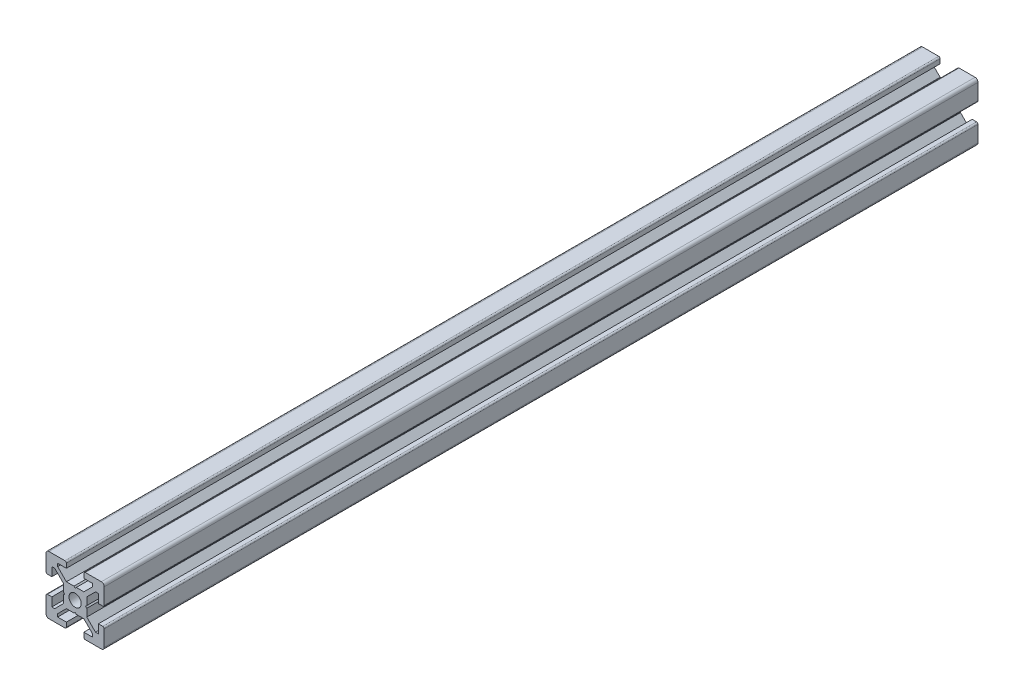
from build123d import *

# Parameters (mm, degrees)
SCHIZZO1_R                   = 2.1
ESTRUSIONE_ESTRUSIONE1_DEPTH = 300


with BuildPart() as part:
    # Schizzo1 → Estrusione-Estrusione1 (new body)
    with BuildSketch(Plane.XY):
        with BuildLine():
            Line((-3.6, 0), (-4, 0.4))
            Line((-4, 0.4), (-4, 3))
            Line((-4, 3), (-7, 6))
            Line((-7, 6), (-8, 6))
            Line((-8, 6), (-8, 3))
            Line((-8, 3), (-9.5, 3))
            ThreePointArc((-9.5, 3), (-9.853553391, 3.146446609), (-10, 3.5))
            Line((-10, 3.5), (-10, 9))
            ThreePointArc((-10, 9), (-9.707106781, 9.707106781), (-9, 10))
            Line((-9, 10), (-3.5, 10))
            ThreePointArc((-3.5, 10), (-3.146446609, 9.853553391), (-3, 9.5))
            Line((-3, 9.5), (-3, 8))
            Line((-3, 8), (-6, 8))
            Line((-6, 8), (-6, 7))
            Line((-6, 7), (-3, 4))
            Line((-3, 4), (-0.4, 4))
            Line((-0.4, 4), (0, 3.6))
            Line((0, 3.6), (0.4, 4))
            Line((0.4, 4), (3, 4))
            Line((3, 4), (6, 7))
            Line((6, 7), (6, 8))
            Line((6, 8), (3, 8))
            Line((3, 8), (3, 9.5))
            ThreePointArc((3, 9.5), (3.146446609, 9.853553391), (3.5, 10))
            Line((3.5, 10), (9, 10))
            ThreePointArc((9, 10), (9.707106781, 9.707106781), (10, 9))
            Line((10, 9), (10, 3.5))
            ThreePointArc((10, 3.5), (9.853553391, 3.146446609), (9.5, 3))
            Line((9.5, 3), (8, 3))
            Line((8, 3), (8, 6))
            Line((8, 6), (7, 6))
            Line((7, 6), (4, 3))
            Line((4, 3), (4, 0.4))
            Line((4, 0.4), (3.6, 0))
            Line((3.6, 0), (4, -0.4))
            Line((4, -0.4), (4, -3))
            Line((4, -3), (7, -6))
            Line((7, -6), (8, -6))
            Line((8, -6), (8, -3))
            Line((8, -3), (9.5, -3))
            ThreePointArc((9.5, -3), (9.853553391, -3.146446609), (10, -3.5))
            Line((10, -3.5), (10, -9))
            ThreePointArc((10, -9), (9.707106781, -9.707106781), (9, -10))
            Line((9, -10), (3.5, -10))
            ThreePointArc((3.5, -10), (3.146446609, -9.853553391), (3, -9.5))
            Line((3, -9.5), (3, -8))
            Line((3, -8), (6, -8))
            Line((6, -8), (6, -7))
            Line((6, -7), (3, -4))
            Line((3, -4), (0.4, -4))
            Line((0.4, -4), (0, -3.6))
            Line((0, -3.6), (-0.4, -4))
            Line((-0.4, -4), (-3, -4))
            Line((-3, -4), (-6, -7))
            Line((-6, -7), (-6, -8))
            Line((-6, -8), (-3, -8))
            Line((-3, -8), (-3, -9.5))
            ThreePointArc((-3, -9.5), (-3.146446609, -9.853553391), (-3.5, -10))
            Line((-3.5, -10), (-9, -10))
            ThreePointArc((-9, -10), (-9.707106781, -9.707106781), (-10, -9))
            Line((-10, -9), (-10, -3.5))
            ThreePointArc((-10, -3.5), (-9.853553391, -3.146446609), (-9.5, -3))
            Line((-9.5, -3), (-8, -3))
            Line((-8, -3), (-8, -6))
            Line((-8, -6), (-7, -6))
            Line((-7, -6), (-4, -3))
            Line((-4, -3), (-4, -0.4))
            Line((-4, -0.4), (-3.6, 0))
        make_face()
        Circle(SCHIZZO1_R, mode=Mode.SUBTRACT)
    extrude(amount=ESTRUSIONE_ESTRUSIONE1_DEPTH)


solid = part.part
